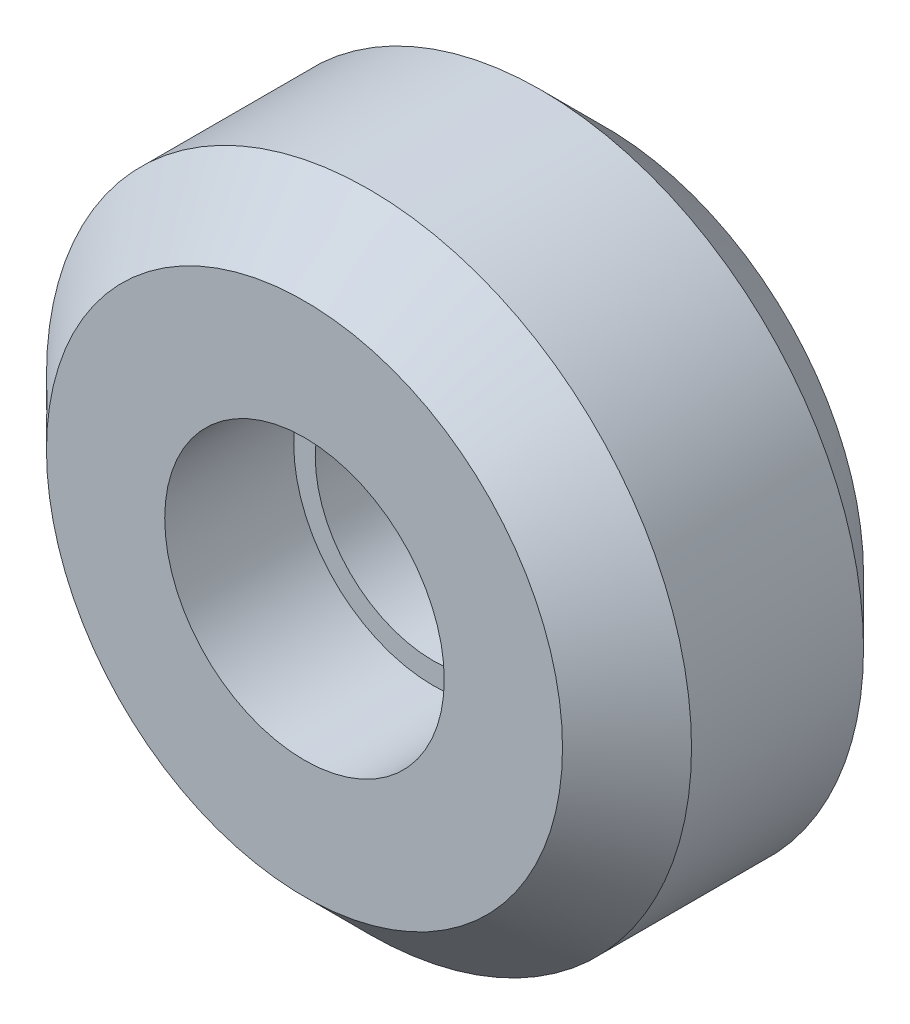
from build123d import *

# Parameters (mm, degrees)
SKETCH1_R           = 15
SKETCH1_R_2         = 5.5
BOSS_EXTRUDE1_DEPTH = 8
SKETCH2_R           = 15
SKETCH2_R_2         = 6.5
BOSS_EXTRUDE2_DEPTH = 6
CHAMFER1_SIZE       = 3


with BuildPart() as part:
    # Sketch1 → Boss-Extrude1 (new body)
    with BuildSketch(Plane.XY):
        Circle(SKETCH1_R)
        Circle(SKETCH1_R_2, mode=Mode.SUBTRACT)
    extrude(amount=BOSS_EXTRUDE1_DEPTH)

    # Sketch2 → Boss-Extrude2 (add)
    with BuildSketch(Plane.XY.offset(8)):
        Circle(SKETCH2_R)
        Circle(SKETCH2_R_2, mode=Mode.SUBTRACT)
    extrude(amount=BOSS_EXTRUDE2_DEPTH)

    # Chamfer1
    chamfer1_edges = [part.edges().sort_by_distance(p)[0] for p in [
        (-15, 0, 14),
        (-15, 0, 0),
    ]]
    chamfer(chamfer1_edges, length=CHAMFER1_SIZE)


solid = part.part
